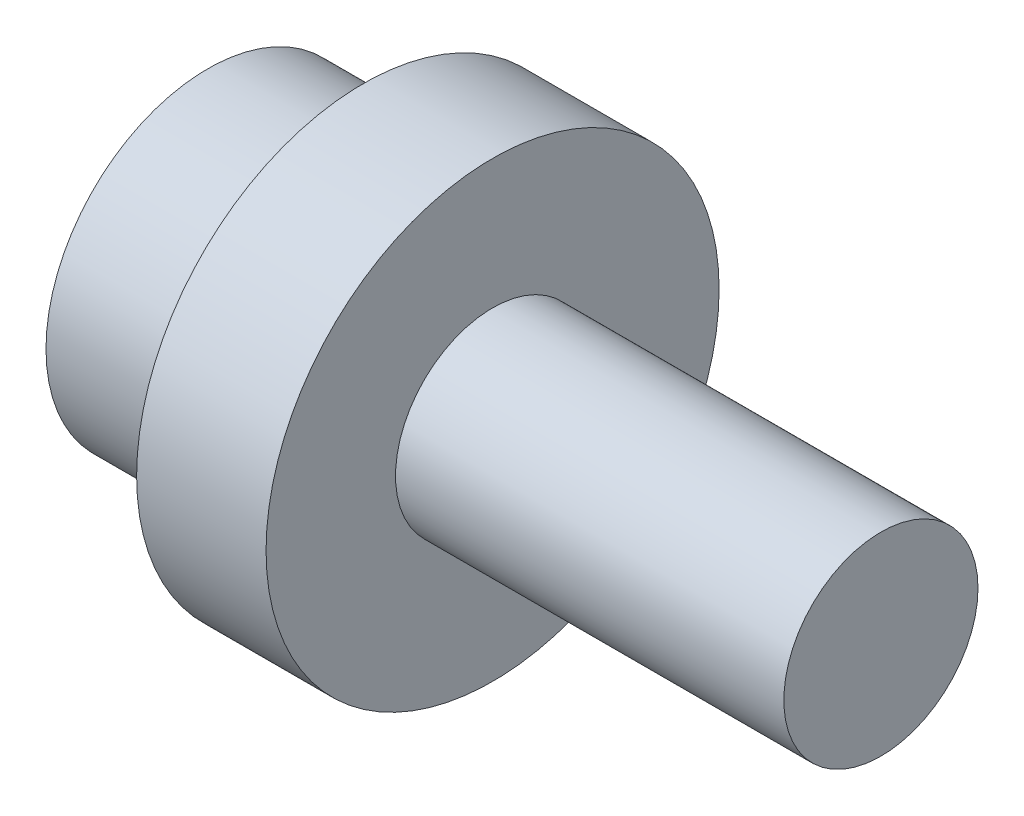
from build123d import *


with BuildPart() as part:
    # Skica1 → Rotovat1 (revolve)
    with BuildSketch(Plane.XY):
        Polygon((0, 0), (0, 12.5), (12, 12.5), (12, 17.5), (22, 17.5), (22, 7.5), (52, 7.5), (52, 0), align=None)
    revolve(axis=Axis((0, 0, 0), (-1, 0, 0)))


solid = part.part
